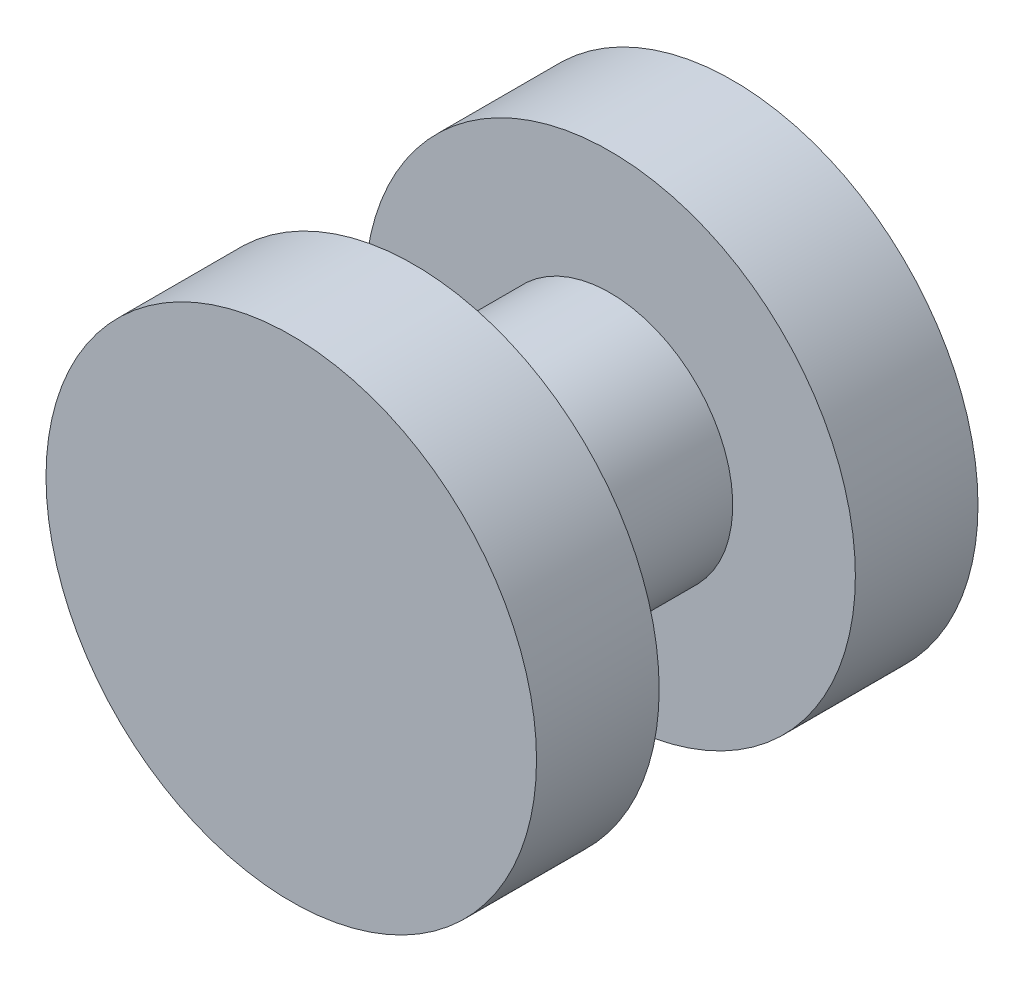
from build123d import *

# Parameters (mm, degrees)
SKETCH1_R           = 3.175
BOSS_EXTRUDE1_DEPTH = 5.08
SKETCH2_R           = 6.35
BOSS_EXTRUDE2_DEPTH = 3.175
SKETCH3_R           = 6.35
BOSS_EXTRUDE3_DEPTH = 3.175


with BuildPart() as part:
    # Sketch1 → Boss-Extrude1 (new body)
    with BuildSketch(Plane.XY):
        Circle(SKETCH1_R)
    extrude(amount=BOSS_EXTRUDE1_DEPTH)

    # Sketch2 → Boss-Extrude2 (add)
    with BuildSketch(Plane(origin=(0, 0, 0), x_dir=(-1, 0, 0), z_dir=(0, 0, -1))):
        Circle(SKETCH2_R)
    extrude(amount=BOSS_EXTRUDE2_DEPTH)

    # Sketch3 → Boss-Extrude3 (add)
    with BuildSketch(Plane.XY.offset(5.08)):
        Circle(SKETCH3_R)
    extrude(amount=BOSS_EXTRUDE3_DEPTH)


solid = part.part
